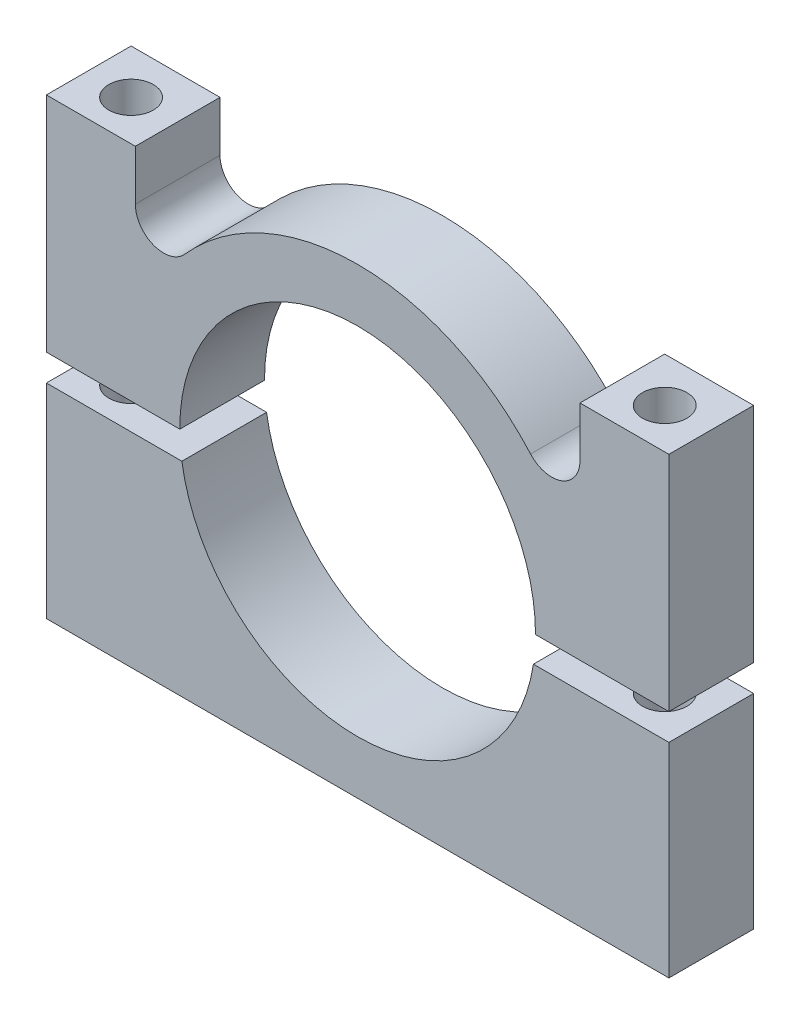
from build123d import *

# Parameters (mm, degrees)
BOSS_EXTRUDE1_DEPTH   = 4.763
BOSS_EXTRUDE1_2_DEPTH = 4.763
SKETCH4_W             = 1.25
SKETCH4_H             = 25.5
SKETCH6_W             = 1.25
SKETCH6_H             = 25.5


with BuildPart() as part:
    # Sketch1 → Boss-Extrude1 (new body)
    with BuildSketch(Plane.XY):
        with BuildLine():
            Line((-17.5, 12.5), (-12.5, 12.5))
            Line((-12.5, 12.5), (-12.5, 9.68052168))
            ThreePointArc((-12.5, 9.68052168), (-11.475926116, 8.196369645), (-9.724935733, 8.627028747))
            ThreePointArc((-9.724935733, 8.627028747), (0, 13), (9.724935733, 8.627028747))
            ThreePointArc((9.724935733, 8.627028747), (11.475926116, 8.196369645), (12.5, 9.68052168))
            Line((12.5, 9.68052168), (12.5, 12.5))
            Line((12.5, 12.5), (17.5, 12.5))
            Line((17.5, 12.5), (17.5, -0.026497455))
            Line((17.5, -0.026497455), (9.999964894, -0.026497455))
            ThreePointArc((9.999964894, -0.026497455), (0, 10), (-9.999964894, -0.026497455))
            Line((-9.999964894, -0.026497455), (-17.5, -0.026497455))
            Line((-17.5, -0.026497455), (-17.5, 12.5))
        make_face()
    extrude(amount=BOSS_EXTRUDE1_DEPTH)


with BuildPart() as body_2:
    # Sketch1 → Boss-Extrude1 2 (new body)
    with BuildSketch(Plane.XY):
        with BuildLine():
            Line((17.5, -13), (-17.5, -13))
            Line((-17.5, -13), (-17.5, -1.526497455))
            Line((-17.5, -1.526497455), (-9.882803525, -1.526497455))
            ThreePointArc((-9.882803525, -1.526497455), (0, -10), (9.882803525, -1.526497455))
            Line((9.882803525, -1.526497455), (17.5, -1.526497455))
            Line((17.5, -1.526497455), (17.5, -13))
        make_face()
    extrude(amount=BOSS_EXTRUDE1_2_DEPTH)


with BuildPart() as tap_drill_for_m3x0_5_tap2_tool:
    # Sketch4 → Tap Drill for M3x0.5 Tap2 (revolve)
    with BuildSketch(Plane(origin=(-15.002809954, 12.5, 2.499998421), x_dir=(0, 0, 1), z_dir=(1, 0, 0))):
        with Locations((0.625, 12.75)):
            Rectangle(SKETCH4_W, SKETCH4_H)
    revolve(axis=Axis((-15.002809954, 18.85, 2.499998421), (0, -1, 0)))


with BuildPart() as part_1:
    add(part.part)

    # Tap Drill for M3x0.5 Tap2: cut by tap_drill_for_m3x0_5_tap2_tool
    add(tap_drill_for_m3x0_5_tap2_tool.part, mode=Mode.SUBTRACT)


with BuildPart() as body_2_1:
    add(body_2.part)

    # Tap Drill for M3x0.5 Tap2: cut by tap_drill_for_m3x0_5_tap2_tool
    add(tap_drill_for_m3x0_5_tap2_tool.part, mode=Mode.SUBTRACT)


with BuildPart() as tap_drill_for_m3x0_5_tap3_tool:
    # Sketch6 → Tap Drill for M3x0.5 Tap3 (revolve)
    with BuildSketch(Plane(origin=(15.002809954, 12.5, 2.499998421), x_dir=(0, 0, 1), z_dir=(1, 0, 0))):
        with Locations((0.625, 12.75)):
            Rectangle(SKETCH6_W, SKETCH6_H)
    revolve(axis=Axis((15.002809954, 18.85, 2.499998421), (0, -1, 0)))


with BuildPart() as part_2:
    add(part_1.part)

    # Tap Drill for M3x0.5 Tap3: cut by tap_drill_for_m3x0_5_tap3_tool
    add(tap_drill_for_m3x0_5_tap3_tool.part, mode=Mode.SUBTRACT)


with BuildPart() as body_2_2:
    add(body_2_1.part)

    # Tap Drill for M3x0.5 Tap3: cut by tap_drill_for_m3x0_5_tap3_tool
    add(tap_drill_for_m3x0_5_tap3_tool.part, mode=Mode.SUBTRACT)


solid = Compound([part_2.part, body_2_2.part])
